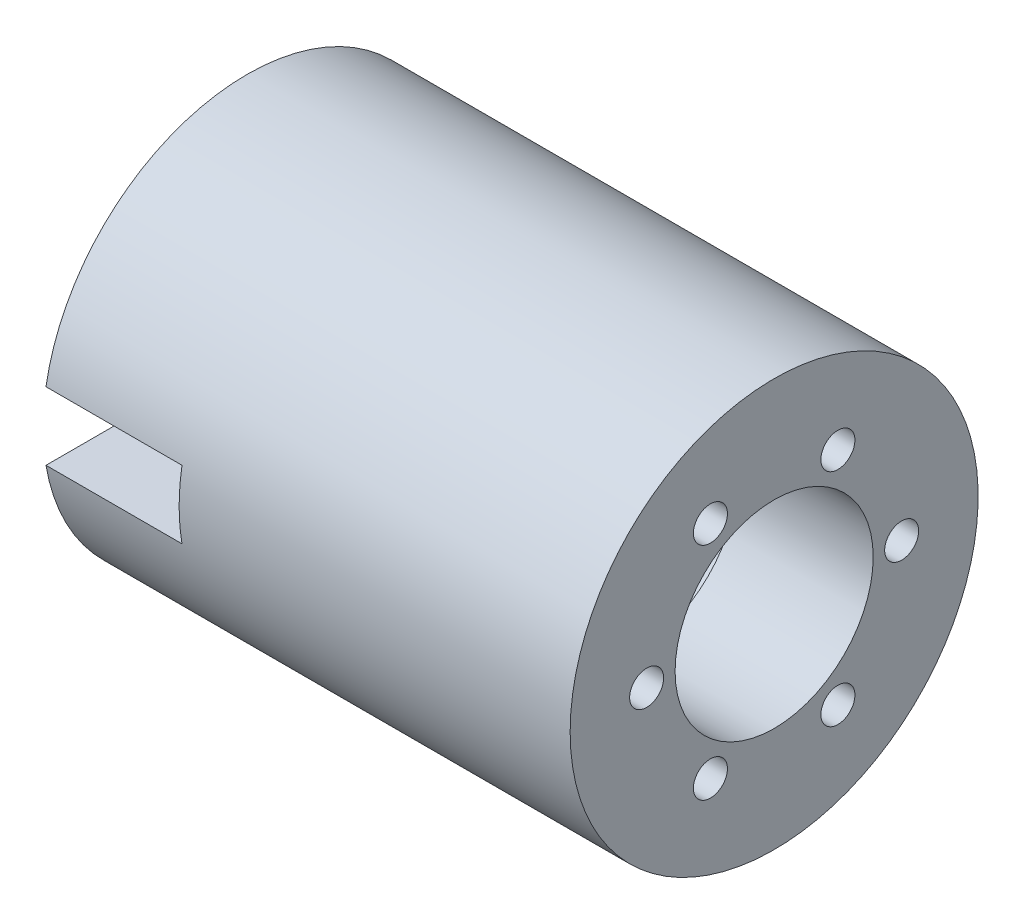
from build123d import *

# Parameters (mm, degrees)
SKETCH1_W          = 25.4
SKETCH1_H          = 5.3975
SKETCH2_R          = 3.175
SKETCH2_R_2        = 18.5
CUT_EXTRUDE1_DEPTH = 25.4
CIRPATTERN1_COUNT  = 6
SKETCH3_W          = 25.4
SKETCH3_H          = 12.7
CUT_EXTRUDE2_DEPTH = 39.1


with BuildPart() as part:
    # Sketch1 → Revolve1 (revolve)
    with BuildSketch(Plane.XY):
        Polygon((-49.2125, 38.1), (-49.2125, 21.2725), (23.8125, 21.2725), (49.2125, 21.2725), (49.2125, 38.1), (42.8625, 38.1), align=None)
        with Locations((36.5125, 18.57375)):
            Rectangle(SKETCH1_W, SKETCH1_H)
    revolve(axis=Axis((-49.2125, 0, 0), (1, 0, 0)))

    # Sketch2 → Cut-Extrude1 (cut)
    with BuildSketch(Plane(origin=(49.2125, 0, 0), x_dir=(0, 0, -1), z_dir=(1, 0, 0))):
        with Locations((-11.90625, -20.622229928)):
            Circle(SKETCH2_R)
        with Locations((11.90625, -20.622229928)):
            Circle(SKETCH2_R)
        with Locations((23.8125, 0)):
            Circle(SKETCH2_R)
        with Locations((11.90625, 20.622229928)):
            Circle(SKETCH2_R)
        with Locations((-11.90625, 20.622229928)):
            Circle(SKETCH2_R)
        Circle(SKETCH2_R_2)
    cut_extrude1 = extrude(amount=-CUT_EXTRUDE1_DEPTH, mode=Mode.SUBTRACT)

    # CirPattern1: Cut-Extrude1 ×6 about axis
    cirpattern1_axis = Axis((-49.2125, 0, 0), (-1, 0, 0))
    for i in range(1, CIRPATTERN1_COUNT):
        add(cut_extrude1.rotate(cirpattern1_axis, i * 360 / CIRPATTERN1_COUNT), mode=Mode.SUBTRACT)

    # Sketch3 → Cut-Extrude2 (cut, through all)
    with BuildSketch(Plane.XY):
        with Locations((-36.5125, 0)):
            Rectangle(SKETCH3_W, SKETCH3_H)
    extrude(amount=CUT_EXTRUDE2_DEPTH, mode=Mode.SUBTRACT)


solid = part.part
